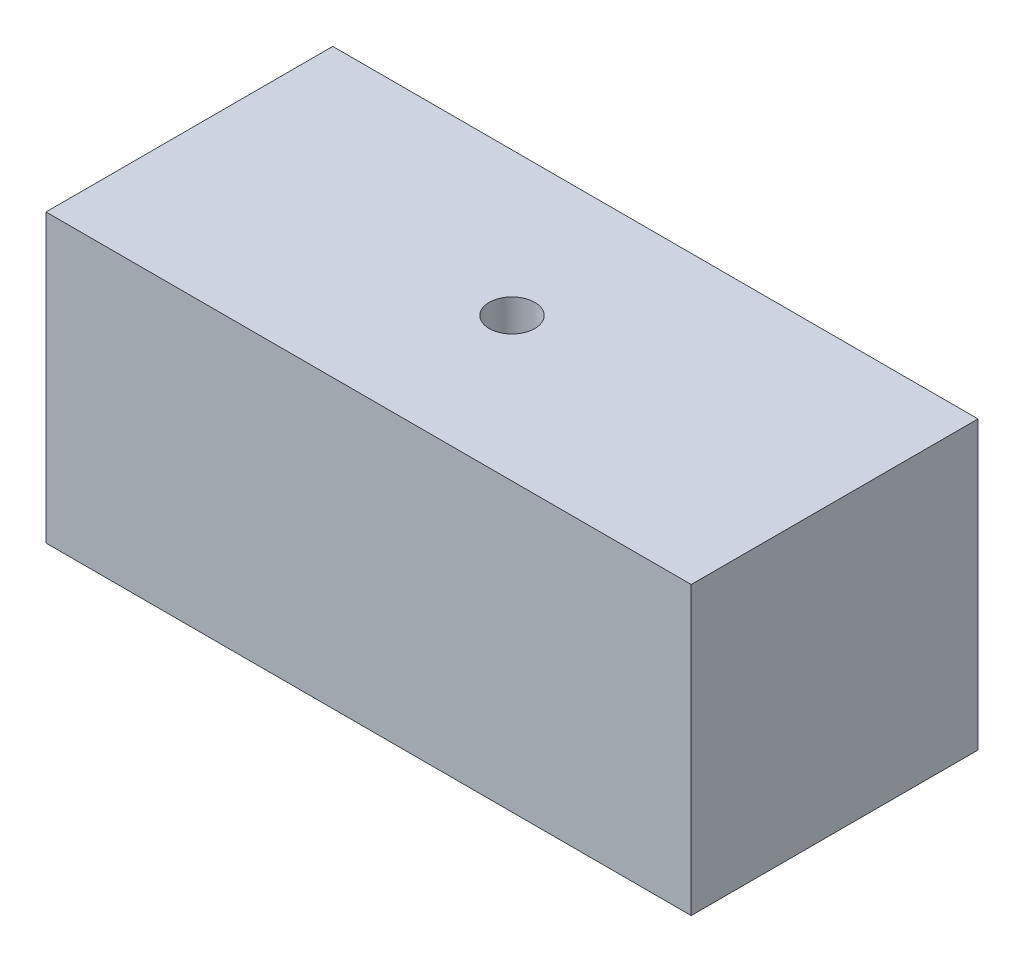
from build123d import *

# Parameters (mm, degrees)
SKETCH1_W           = 90
SKETCH1_H           = 40
BOSS_EXTRUDE1_DEPTH = 40
SKETCH2_R           = 10
BOSS_EXTRUDE2_DEPTH = 5
SKETCH3_R           = 3.175
CUT_EXTRUDE1_DEPTH  = 41


with BuildPart() as part:
    # Sketch1 → Boss-Extrude1 (new body)
    with BuildSketch(Plane(origin=(0, 0, 0), x_dir=(1, 0, 0), z_dir=(0, 1, 0))):
        Rectangle(SKETCH1_W, SKETCH1_H)
    extrude(amount=BOSS_EXTRUDE1_DEPTH)

    # Sketch2 → Boss-Extrude2 (add)
    with BuildSketch(Plane(origin=(0, 0, -20), x_dir=(-1, 0, 0), z_dir=(0, 0, -1))):
        with Locations((-25, 20)):
            Circle(SKETCH2_R)
    extrude(amount=BOSS_EXTRUDE2_DEPTH)

    # Sketch3 → Cut-Extrude1 (cut, through all)
    with BuildSketch(Plane(origin=(0, 40, 0), x_dir=(1, 0, 0), z_dir=(0, 1, 0))):
        Circle(SKETCH3_R)
    extrude(amount=-CUT_EXTRUDE1_DEPTH, mode=Mode.SUBTRACT)


solid = part.part
